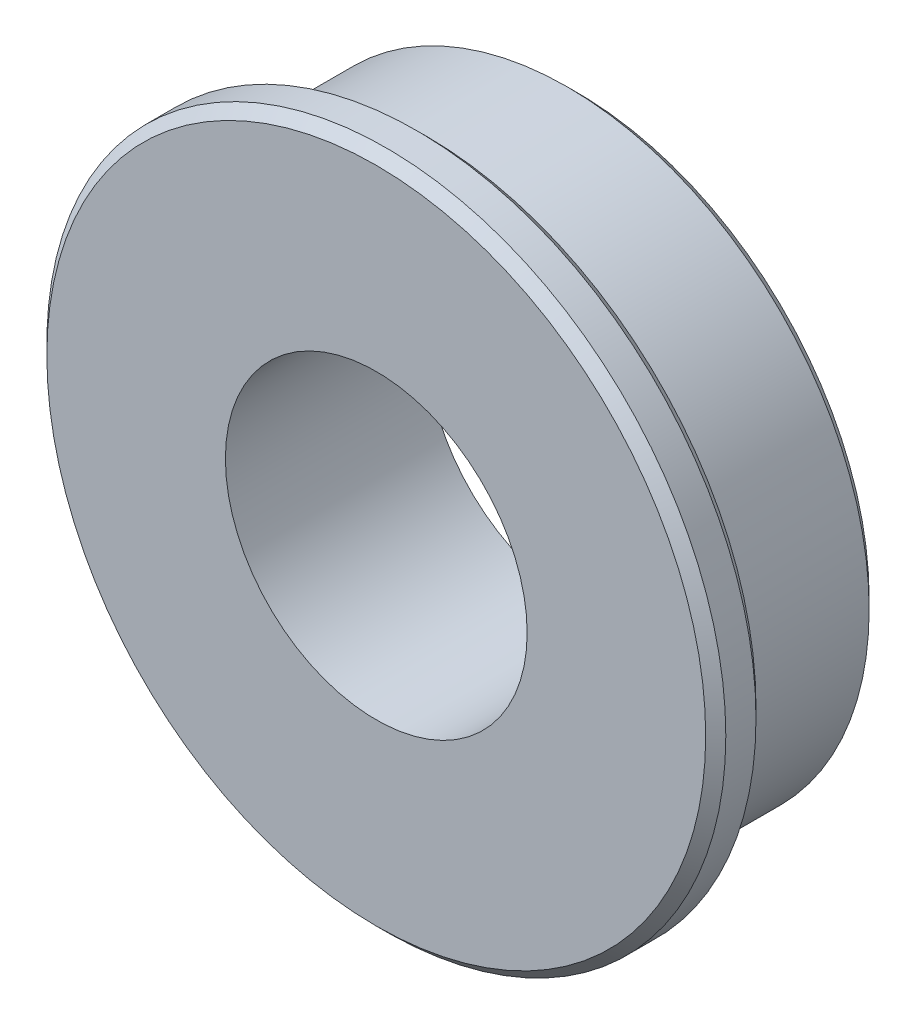
from build123d import *

# Parameters (mm, degrees)
SKETCH_1_R      = 6
SKETCH_1_R_2    = 3
EXTRUDE_1_DEPTH = 2
SKETCH_2_R      = 6.75
SKETCH_2_R_2    = 3
EXTRUDE_2_DEPTH = 1
CHAMFER_1_SIZE  = 0.2


with BuildPart() as part:
    # 草图1 → 凸台-拉伸1 (new body, symmetric)
    with BuildSketch(Plane.XY):
        Circle(SKETCH_1_R)
        Circle(SKETCH_1_R_2, mode=Mode.SUBTRACT)
    extrude(amount=EXTRUDE_1_DEPTH, both=True)

    # 草图2 → 凸台-拉伸2 (add)
    with BuildSketch(Plane.XY.offset(2)):
        Circle(SKETCH_2_R)
        Circle(SKETCH_2_R_2, mode=Mode.SUBTRACT)
    extrude(amount=-EXTRUDE_2_DEPTH)

    # 倒角1
    chamfer_1_edges = [part.edges().sort_by_distance(p)[0] for p in [
        (-6.75, 0, 2),
        (-6.75, 0, 1),
        (-6, 0, -2),
    ]]
    chamfer(chamfer_1_edges, length=CHAMFER_1_SIZE)


solid = part.part
